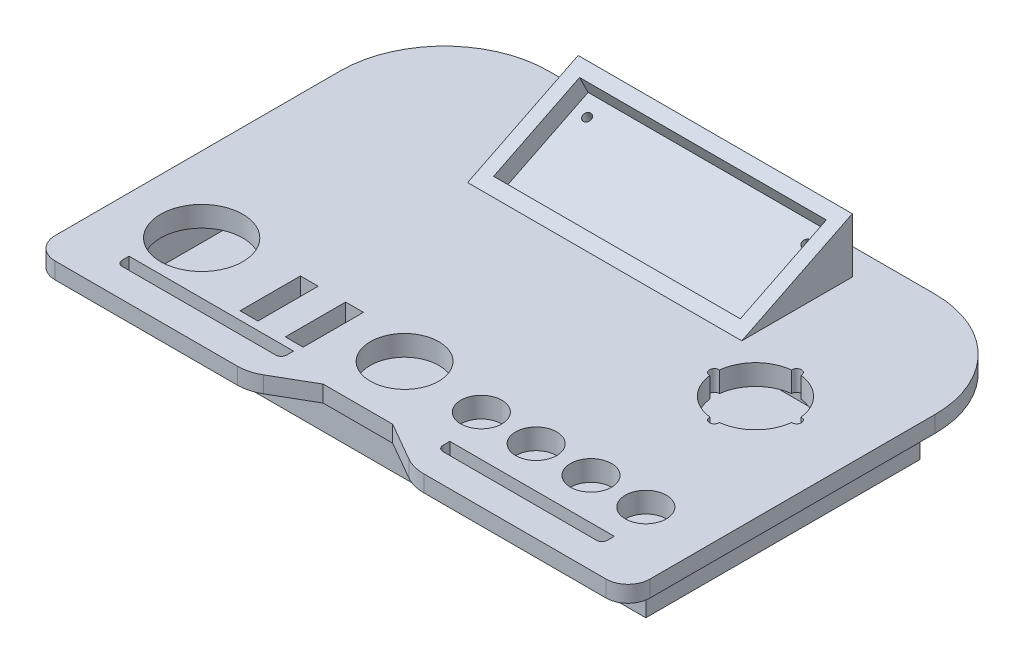
from build123d import *

# Parameters (mm, degrees)
IZIM2_W                     = 200
IZIM2_H                     = 100
Y_KSEKLIK_EKSTR_ZYON1_DEPTH = 20
IZIM3_R                     = 7.5
IZIM3_R_2                   = 12.5
IZIM3_R_3                   = 15
IZIM3_W                     = 6.5
IZIM3_H                     = 22
KES_EKSTR_ZYON11_DEPTH      = 12
Y_KSEKLIK_EKSTR_ZYON2_DEPTH = 6
Y_KSEKLIK_EKSTR_ZYON3_DEPTH = 50
IZIM9_W                     = 90
IZIM9_H                     = 35
KES_EKSTR_ZYON12_DEPTH      = 7
IZIM12_R                    = 1.5
KES_EKSTR_ZYON14_DEPTH      = 34.138350552
IZIM15_W                    = 196
IZIM15_H                    = 11
KES_EKSTR_ZYON15_DEPTH      = 92
IZIM16_R                    = 1.5
KES_EKSTR_ZYON16_DEPTH      = 10


with BuildPart() as part:
    # Çizim2 → Yükseklik-Ekstrüzyon1 (new body)
    with BuildSketch(Plane(origin=(0, 0, 0), x_dir=(1, 0, 0), z_dir=(0, 1, 0))):
        with Locations((-100, 50)):
            Rectangle(IZIM2_W, IZIM2_H)
    extrude(amount=Y_KSEKLIK_EKSTR_ZYON1_DEPTH)

    # Çizim3 → Kes-Ekstrüzyon11 (cut)
    with BuildSketch(Plane(origin=(0, 20, 0), x_dir=(1, 0, 0), z_dir=(0, 1, 0))):
        with Locations((-15, 15)):
            Circle(IZIM3_R)
        with Locations((-35, 15)):
            Circle(IZIM3_R)
        with Locations((-55, 15)):
            Circle(IZIM3_R)
        with Locations((-75, 15)):
            Circle(IZIM3_R)
        with Locations((-105, 17)):
            Circle(IZIM3_R_2)
        with Locations((-181, 19)):
            Circle(IZIM3_R_3)
        with Locations((-147.75, 14)):
            Rectangle(IZIM3_W, IZIM3_H)
        with Locations((-131.25, 14)):
            Rectangle(IZIM3_W, IZIM3_H)
        with BuildLine():
            ThreePointArc((-44.897916667, 68.252979968), (-40.606601718, 59.393398282), (-31.747020032, 55.102083333))
            ThreePointArc((-31.747020032, 55.102083333), (-30, 53.25), (-28.252979968, 55.102083333))
            ThreePointArc((-28.252979968, 55.102083333), (-19.393398282, 59.393398282), (-15.102083333, 68.252979968))
            ThreePointArc((-15.102083333, 68.252979968), (-13.25, 70), (-15.102083333, 71.747020032))
            ThreePointArc((-15.102083333, 71.747020032), (-19.393398282, 80.606601718), (-28.252979968, 84.897916667))
            ThreePointArc((-28.252979968, 84.897916667), (-30, 86.75), (-31.747020032, 84.897916667))
            ThreePointArc((-31.747020032, 84.897916667), (-40.606601718, 80.606601718), (-44.897916667, 71.747020032))
            ThreePointArc((-44.897916667, 71.747020032), (-46.75, 70), (-44.897916667, 68.252979968))
        make_face()
    extrude(amount=-KES_EKSTR_ZYON11_DEPTH, mode=Mode.SUBTRACT)

    # Çizim7 → Yükseklik-Ekstrüzyon2 (add)
    with BuildSketch(Plane(origin=(0, 20, 0), x_dir=(1, 0, 0), z_dir=(0, 1, 0))):
        with BuildLine():
            Line((-112.679491924, -5), (-87.320508076, -5))
            Line((-87.320508076, -5), (-73.480762114, -12.990381057))
            ThreePointArc((-73.480762114, -12.990381057), (-69.86304779, -14.488887394), (-65.980762114, -15))
            Line((-65.980762114, -15), (0.5, -15))
            ThreePointArc((0.5, -15), (6.156854249, -12.656854249), (8.5, -7))
            Line((8.5, -7), (8.5, 97))
            ThreePointArc((8.5, 97), (-2.629942315, 123.870057685), (-29.5, 135))
            Line((-29.5, 135), (-170.5, 135))
            ThreePointArc((-170.5, 135), (-197.370057685, 123.870057685), (-208.5, 97))
            Line((-208.5, 97), (-208.5, -7))
            ThreePointArc((-208.5, -7), (-206.156854249, -12.656854249), (-200.5, -15))
            Line((-200.5, -15), (-134.019237886, -15))
            ThreePointArc((-134.019237886, -15), (-130.13695221, -14.488887394), (-126.519237886, -12.990381057))
            Line((-126.519237886, -12.990381057), (-112.679491924, -5))
        make_face()
        with BuildLine():
            Line((-71.5, 0), (-128.5, 0))
            Line((-128.5, 0), (-128.5, -2.5))
            ThreePointArc((-128.5, -2.5), (-129.085786438, -3.914213562), (-130.5, -4.5))
            Line((-130.5, -4.5), (-186.5, -4.5))
            ThreePointArc((-186.5, -4.5), (-187.914213562, -3.914213562), (-188.5, -2.5))
            Line((-188.5, -2.5), (-188.5, 0))
            Line((-188.5, 0), (-200, 0))
            Line((-200, 0), (-200, 100))
            Line((-200, 100), (0, 100))
            Line((0, 100), (0, 0))
            Line((0, 0), (-11.5, 0))
            Line((-11.5, 0), (-11.5, -2.5))
            ThreePointArc((-11.5, -2.5), (-12.085786438, -3.914213562), (-13.5, -4.5))
            Line((-13.5, -4.5), (-69.5, -4.5))
            ThreePointArc((-69.5, -4.5), (-70.914213562, -3.914213562), (-71.5, -2.5))
            Line((-71.5, -2.5), (-71.5, 0))
        make_face(mode=Mode.SUBTRACT)
    extrude(amount=-Y_KSEKLIK_EKSTR_ZYON2_DEPTH)

    # Çizim8 → Yükseklik-Ekstrüzyon3 (add, symmetric)
    with BuildSketch(Plane(origin=(-100, 0, 0), x_dir=(0, 0, -1), z_dir=(1, 0, 0))):
        Polygon((85, 20), (125.311288741, 40), (125.311288741, 20), align=None)
    extrude(amount=Y_KSEKLIK_EKSTR_ZYON3_DEPTH, both=True)

    # Çizim9 → Kes-Ekstrüzyon12 (cut)
    with BuildSketch(Plane(origin=(0, -17.792193018, -8.827399755), x_dir=(1, 0, 0), z_dir=(0, 0.895806416, 0.444444444))):
        with Locations((-100, 107.532434289)):
            Rectangle(IZIM9_W, IZIM9_H)
    extrude(amount=-KES_EKSTR_ZYON12_DEPTH, mode=Mode.SUBTRACT)

    # Çizim12 → Kes-Ekstrüzyon14 (cut, through all)
    with BuildSketch(Plane(origin=(0, -24.062837933, -11.938510866), x_dir=(1, 0, 0), z_dir=(0, 0.895806416, 0.444444444))):
        with Locations((-140, 119.032434289)):
            Circle(IZIM12_R)
        with Locations((-60, 119.032434289)):
            Circle(IZIM12_R)
    extrude(amount=-KES_EKSTR_ZYON14_DEPTH, mode=Mode.SUBTRACT)

    # Çizim15 → Kes-Ekstrüzyon15 (cut)
    with BuildSketch(Plane(origin=(0, 0, -95), x_dir=(-1, 0, 0), z_dir=(0, 0, -1))):
        with Locations((100, 7)):
            Rectangle(IZIM15_W, IZIM15_H)
    extrude(amount=-KES_EKSTR_ZYON15_DEPTH, mode=Mode.SUBTRACT)

    # Çizim16 → Kes-Ekstrüzyon16 (cut)
    with BuildSketch(Plane(origin=(0, 0, -100), x_dir=(-1, 0, 0), z_dir=(0, 0, -1))):
        with Locations((65, 8)):
            Circle(IZIM16_R)
        with Locations((135, 8)):
            Circle(IZIM16_R)
    extrude(amount=-KES_EKSTR_ZYON16_DEPTH, mode=Mode.SUBTRACT)


solid = part.part
